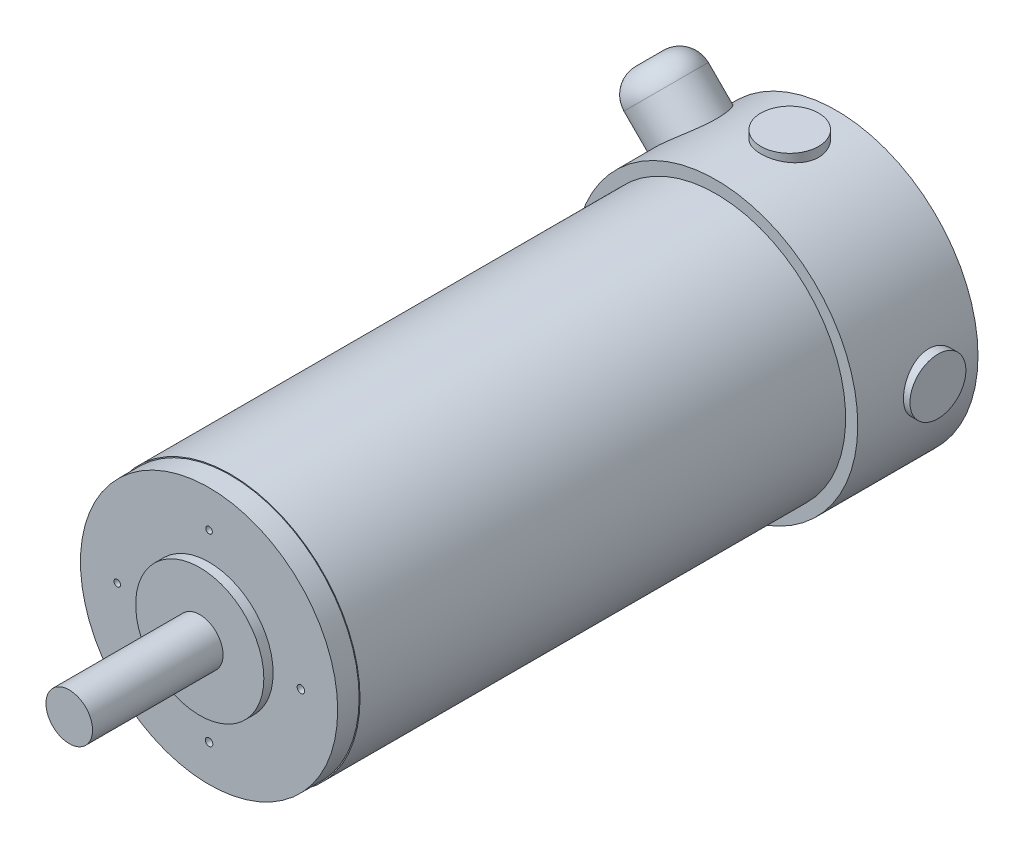
from build123d import *

# Parameters (mm, degrees)
SKETCH1_R            = 35.306
SKETCH1_R_2          = 1.016
BASE_EXTRUDE_DEPTH   = 165.1
SKETCH2_R            = 38.608
BOSS_EXTRUDE1_DEPTH  = 32.766
SKETCH3_R            = 6.35
BOSS_EXTRUDE2_DEPTH  = 43.942
SKETCH4_R            = 17.4625
BOSS_EXTRUDE3_DEPTH  = 8.382
SKETCH7_R            = 7.874
BOSS_EXTRUDE5_DEPTH  = 40.386
SKETCH9_R            = 7.62
BOSS_EXTRUDE7_DEPTH  = 80.772
SKETCH11_R           = 7.874
BOSS_EXTRUDE8_DEPTH  = 40.386
BOSS_EXTRUDE10_START = -80.772
SKETCH12_R           = 7.874
BOSS_EXTRUDE10_DEPTH = 80.772
SKETCH13_R           = 9.398
BOSS_EXTRUDE11_DEPTH = 53.975
FILLET1_R            = 6.35
BOSS_EXTRUDE12_START = 16.002
SKETCH14_R           = 6.35
BOSS_EXTRUDE12_DEPTH = 16.002
SKETCH15_R           = 35.052
SKETCH15_R_2         = 1.016
SKETCH15_R_3         = 0.889
BOSS_EXTRUDE13_DEPTH = 5.842


with BuildPart() as part:
    # Sketch1 → Base-Extrude (new body)
    with BuildSketch(Plane.XY):
        Circle(SKETCH1_R)
        with Locations((25.019, 0)):
            Circle(SKETCH1_R_2, mode=Mode.SUBTRACT)
        with Locations((0, 25.019)):
            Circle(SKETCH1_R_2, mode=Mode.SUBTRACT)
        with Locations((-25.019, 0)):
            Circle(SKETCH1_R_2, mode=Mode.SUBTRACT)
        with Locations((0, -25.019)):
            Circle(SKETCH1_R_2, mode=Mode.SUBTRACT)
    extrude(amount=BASE_EXTRUDE_DEPTH)

    # Sketch2 → Boss-Extrude1 (add)
    with BuildSketch(Plane(origin=(0, 0, 0), x_dir=(-1, 0, 0), z_dir=(0, 0, -1))):
        Circle(SKETCH2_R)
    extrude(amount=-BOSS_EXTRUDE1_DEPTH)

    # Sketch3 → Boss-Extrude2 (add)
    with BuildSketch(Plane.XY.offset(165.1)):
        Circle(SKETCH3_R)
    extrude(amount=BOSS_EXTRUDE2_DEPTH)

    # Sketch4 → Boss-Extrude3 (add)
    with BuildSketch(Plane.XY.offset(165.1)):
        Circle(SKETCH4_R)
    extrude(amount=BOSS_EXTRUDE3_DEPTH)

    # Sketch7 → Boss-Extrude5 (add)
    with BuildSketch(Plane(origin=(0, 0, 0), x_dir=(0, 0, -1), z_dir=(1, 0, 0))):
        with Locations((-12.7, 0)):
            Circle(SKETCH7_R)
    extrude(amount=-BOSS_EXTRUDE5_DEPTH)

    # Sketch9 → Boss-Extrude7 (add)
    with BuildSketch(Plane.ZY.offset(40.386)):
        with Locations((12.7, 0)):
            Circle(SKETCH9_R)
    extrude(amount=-BOSS_EXTRUDE7_DEPTH)

    # Sketch11 → Boss-Extrude8 (add)
    with BuildSketch(Plane(origin=(0, 0, 0), x_dir=(-1, 0, 0), z_dir=(0, 1, 0))):
        with Locations((0, 12.7)):
            Circle(SKETCH11_R)
    extrude(amount=BOSS_EXTRUDE8_DEPTH)

    # Sketch12 → Boss-Extrude10 (add)
    with BuildSketch(Plane(origin=(0, 40.386, 0), x_dir=(-1, 0, 0), z_dir=(0, 1, 0)).offset(BOSS_EXTRUDE10_START)):
        with Locations((0, 12.7)):
            Circle(SKETCH12_R)
    extrude(amount=BOSS_EXTRUDE10_DEPTH)

    # Sketch13 → Boss-Extrude11 (add)
    with BuildSketch(Plane(origin=(0, 0, 0), x_dir=(0, 0, 1), z_dir=(-0.7071067811865488, 0.7071067811865462, 0))):
        with Locations((12.7, 0)):
            Circle(SKETCH13_R)
    extrude(amount=BOSS_EXTRUDE11_DEPTH)

    # Fillet1
    fillet1_edges = [part.edges().sort_by_distance(p)[0] for p in [
        (-38.166088515, 38.166088515, 3.302),
    ]]
    fillet(fillet1_edges, radius=FILLET1_R)

    # Sketch14 → Boss-Extrude12 (add)
    with BuildSketch(Plane(origin=(0, 0, 0), x_dir=(-1, 0, 0), z_dir=(0, 0, -1)).offset(BOSS_EXTRUDE12_START)):
        Circle(SKETCH14_R)
    extrude(amount=-BOSS_EXTRUDE12_DEPTH)

    # Sketch15 → Boss-Extrude13 (add)
    with BuildSketch(Plane.XY.offset(165.1)):
        Circle(SKETCH15_R)
        with Locations((25.019, 0)):
            Circle(SKETCH15_R_2, mode=Mode.SUBTRACT)
        with Locations((0, 25.019)):
            Circle(SKETCH15_R_3, mode=Mode.SUBTRACT)
        with Locations((0, -25.019)):
            Circle(SKETCH15_R_2, mode=Mode.SUBTRACT)
        with Locations((-25.019, 0)):
            Circle(SKETCH15_R_3, mode=Mode.SUBTRACT)
    extrude(amount=BOSS_EXTRUDE13_DEPTH)


solid = part.part
